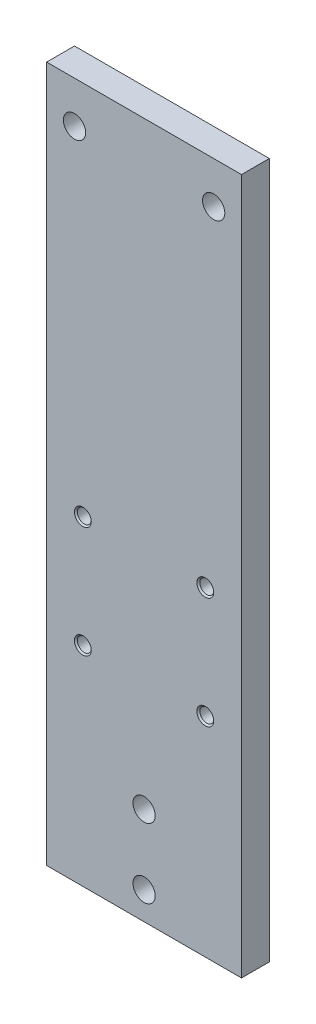
from build123d import *

# Parameters (mm, degrees)
SKETCH1_W                       = 70
SKETCH1_H                       = 250
SKETCH1_R                       = 4
BOSS_EXTRUDE1_DEPTH             = 10
M6X1_0_TAPPED_HOLE2_D           = 5
M6X1_0_TAPPED_HOLE2_CSINK_D     = 6.05
M6X1_0_TAPPED_HOLE2_CSINK_ANGLE = 90
SKETCH7_R                       = 4
CUT_EXTRUDE1_DEPTH              = 11


with BuildPart() as part:
    # Sketch1 → Boss-Extrude1 (new body)
    with BuildSketch(Plane.XY):
        Rectangle(SKETCH1_W, SKETCH1_H)
        with Locations((-25, 110)):
            Circle(SKETCH1_R, mode=Mode.SUBTRACT)
        with Locations((25, 110)):
            Circle(SKETCH1_R, mode=Mode.SUBTRACT)
    extrude(amount=BOSS_EXTRUDE1_DEPTH)

    # M6x1.0 Tapped Hole2 (through all)
    with Locations(Plane.XY.offset(10)):
        with Locations((-22, -10), (22, -10), (22, -50), (-22, -50)):
            CounterSinkHole(M6X1_0_TAPPED_HOLE2_D / 2, M6X1_0_TAPPED_HOLE2_CSINK_D / 2, counter_sink_angle=M6X1_0_TAPPED_HOLE2_CSINK_ANGLE)

    # Sketch7 → Cut-Extrude1 (cut, through all)
    with BuildSketch(Plane.XY.offset(10)):
        with Locations((0, -90)):
            Circle(SKETCH7_R)
        with Locations((0, -115)):
            Circle(SKETCH7_R)
    extrude(amount=-CUT_EXTRUDE1_DEPTH, mode=Mode.SUBTRACT)


solid = part.part
